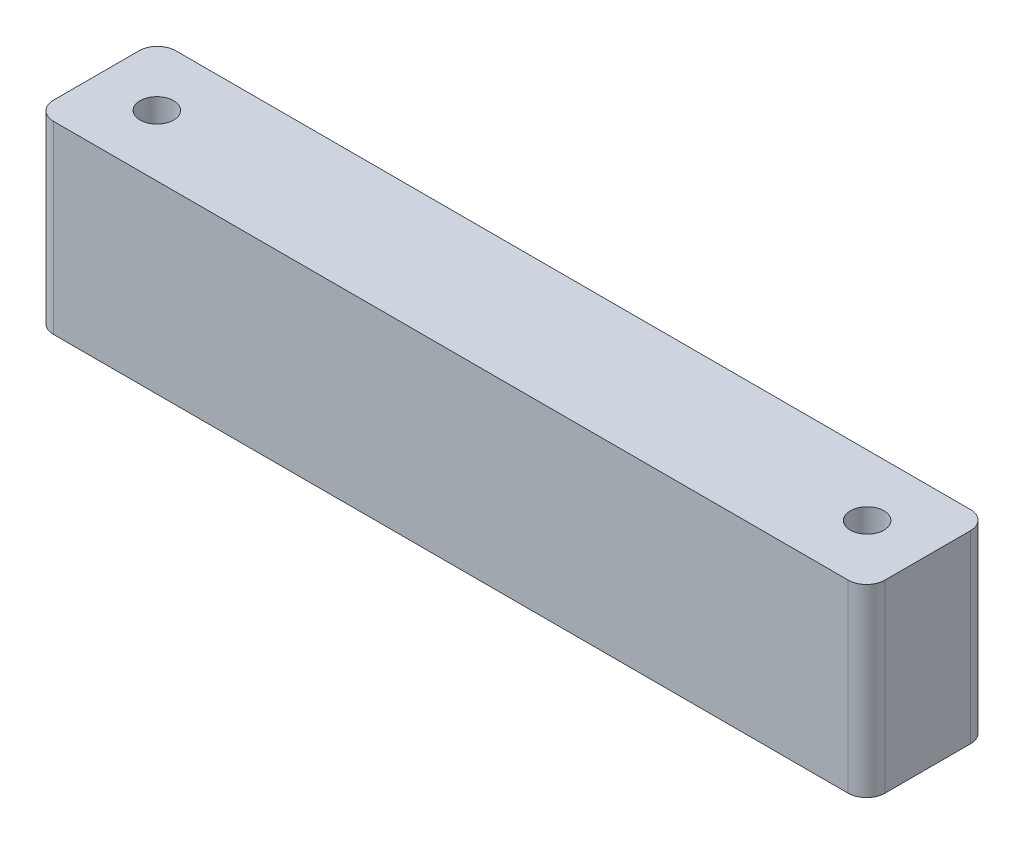
from build123d import *

# Parameters (mm, degrees)
BOSS_EXTRUDE1_DEPTH      = 30.2
M5_CLEARANCE_HOLE1_D     = 5.5
M5_CLEARANCE_HOLE1_DEPTH = 30.2


with BuildPart() as part:
    # Sketch1 → Boss-Extrude1 (new body)
    with BuildSketch(Plane(origin=(0, 0, 0), x_dir=(1, 0, 0), z_dir=(0, 1, 0))):
        with BuildLine():
            Line((65, -10), (-65, -10))
            ThreePointArc((-65, -10), (-67.121320344, -9.121320344), (-68, -7))
            Line((-68, -7), (-68, 7))
            ThreePointArc((-68, 7), (-67.121320344, 9.121320344), (-65, 10))
            Line((-65, 10), (65, 10))
            ThreePointArc((65, 10), (67.121320344, 9.121320344), (68, 7))
            Line((68, 7), (68, -7))
            ThreePointArc((68, -7), (67.121320344, -9.121320344), (65, -10))
        make_face()
    extrude(amount=BOSS_EXTRUDE1_DEPTH)

    # M5 Clearance Hole1
    with Locations(Plane(origin=(0, 30.2, 0), x_dir=(1, 0, 0), z_dir=(0, 1, 0))):
        with Locations((-58.1, 0), (58.1, 0)):
            Hole(M5_CLEARANCE_HOLE1_D / 2, depth=M5_CLEARANCE_HOLE1_DEPTH)


solid = part.part
